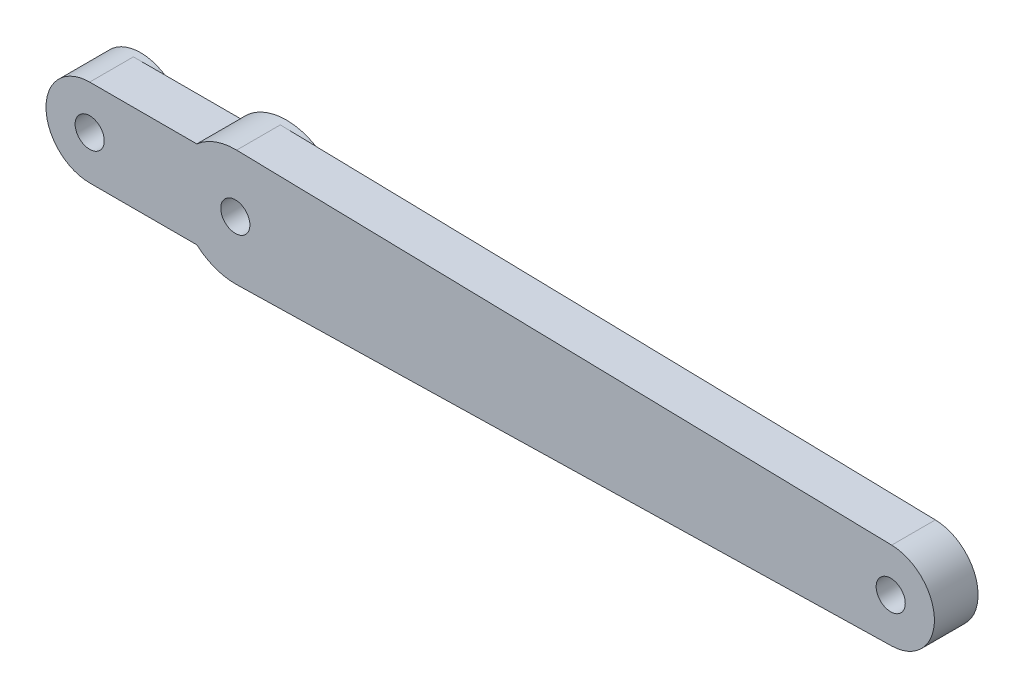
from build123d import *

# Parameters (mm, degrees)
SKETCH1_R           = 1
BOSS_EXTRUDE1_DEPTH = 3
SKETCH2_R           = 3
SKETCH2_R_2         = 1
SKETCH2_R_3         = 4
BOSS_EXTRUDE2_DEPTH = 0.5


with BuildPart() as part:
    # Sketch1 → Boss-Extrude1 (new body)
    with BuildSketch(Plane.XY):
        with BuildLine():
            ThreePointArc((-2.645751311, -3), (-1.372549714, -3.757140839), (0.088888889, -3.999012224))
            Line((0.088888889, -3.999012224), (45.066666667, -2.999259168))
            ThreePointArc((45.066666667, -2.999259168), (48, 0), (45.066666667, 2.999259168))
            Line((45.066666667, 2.999259168), (0.088888889, 3.999012224))
            ThreePointArc((0.088888889, 3.999012224), (-1.372549714, 3.757140839), (-2.645751311, 3))
            Line((-2.645751311, 3), (-10, 3))
            ThreePointArc((-10, 3), (-13, 0), (-10, -3))
            Line((-10, -3), (-2.645751311, -3))
        make_face()
        Circle(SKETCH1_R, mode=Mode.SUBTRACT)
        with Locations((-10, 0)):
            Circle(SKETCH1_R, mode=Mode.SUBTRACT)
        with Locations((45, 0)):
            Circle(SKETCH1_R, mode=Mode.SUBTRACT)
    extrude(amount=BOSS_EXTRUDE1_DEPTH)

    # Sketch2 → Boss-Extrude2 (add)
    with BuildSketch(Plane(origin=(0, 0, 0), x_dir=(-1, 0, 0), z_dir=(0, 0, -1))):
        with Locations((10, 0)):
            Circle(SKETCH2_R)
        with Locations((10, 0)):
            Circle(SKETCH2_R_2, mode=Mode.SUBTRACT)
        Circle(SKETCH2_R_3)
        Circle(SKETCH2_R_2, mode=Mode.SUBTRACT)
    extrude(amount=BOSS_EXTRUDE2_DEPTH)


solid = part.part
